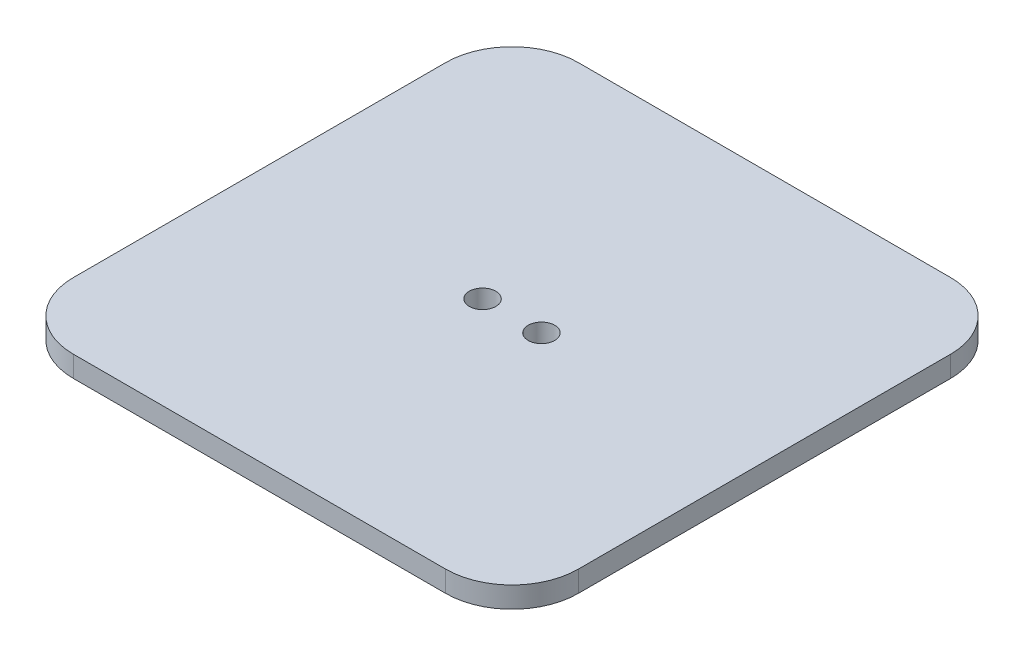
from build123d import *

# Parameters (mm, degrees)
SKETCH1_W           = 76.2
SKETCH1_H           = 76.2
BOSS_EXTRUDE1_DEPTH = 3.175
FILLET1_R           = 10
FILLET2_R           = 10
FILLET3_R           = 10
FILLET4_R           = 10
SKETCH2_R           = 2
CUT_EXTRUDE1_DEPTH  = 54.975


with BuildPart() as part:
    # Sketch1 → Boss-Extrude1 (new body)
    with BuildSketch(Plane(origin=(0, 0, 0), x_dir=(1, 0, 0), z_dir=(0, 1, 0))):
        Rectangle(SKETCH1_W, SKETCH1_H)
    extrude(amount=BOSS_EXTRUDE1_DEPTH)

    # Fillet1
    fillet1_edges = [part.edges().sort_by_distance(p)[0] for p in [
        (-38.1, 1.5875, 38.1),
    ]]
    fillet(fillet1_edges, radius=FILLET1_R)

    # Fillet2
    fillet2_edges = [part.edges().sort_by_distance(p)[0] for p in [
        (-38.1, 1.5875, -38.1),
    ]]
    fillet(fillet2_edges, radius=FILLET2_R)

    # Fillet3
    fillet3_edges = [part.edges().sort_by_distance(p)[0] for p in [
        (38.1, 1.5875, -38.1),
    ]]
    fillet(fillet3_edges, radius=FILLET3_R)

    # Fillet4
    fillet4_edges = [part.edges().sort_by_distance(p)[0] for p in [
        (38.1, 1.5875, 38.1),
    ]]
    fillet(fillet4_edges, radius=FILLET4_R)

    # Sketch2 → Cut-Extrude1 (cut, through all)
    with BuildSketch(Plane(origin=(0, 3.175, 0), x_dir=(1, 0, 0), z_dir=(0, 1, 0))):
        with Locations((4.445, 0)):
            Circle(SKETCH2_R)
        with Locations((-4.445, 0)):
            Circle(SKETCH2_R)
    extrude(amount=-CUT_EXTRUDE1_DEPTH, mode=Mode.SUBTRACT)


solid = part.part
